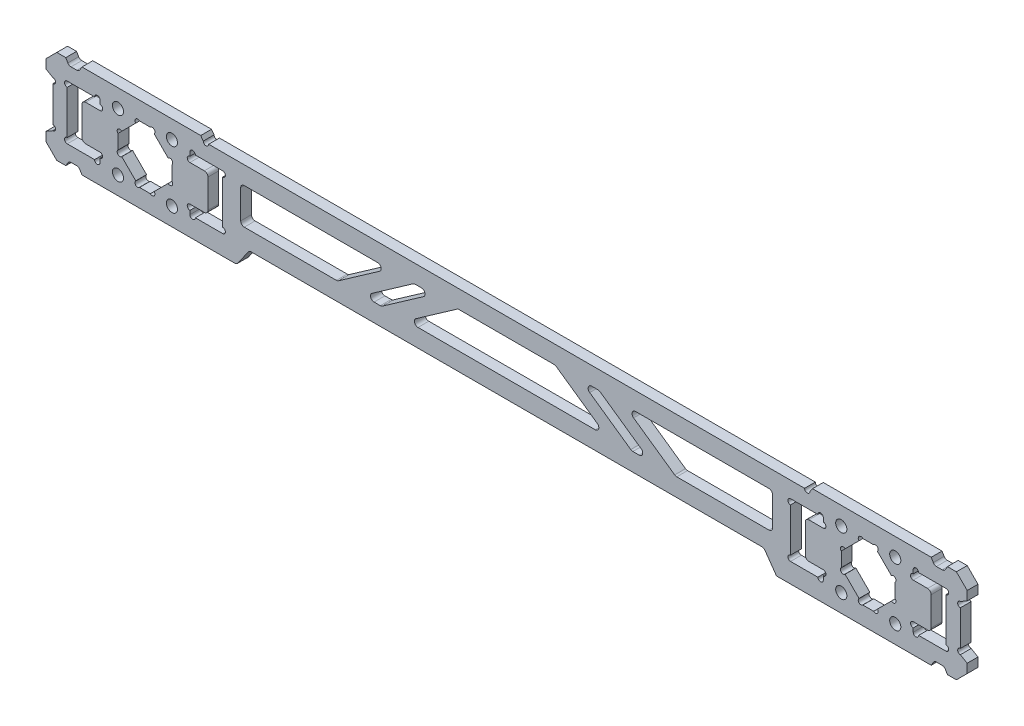
from build123d import *

# Parameters (mm, degrees)
SKETCH_1_W           = 256
SKETCH_1_H           = 26
SKETCH_1_R           = 1.55
EXTRUDE_1_DEPTH      = 1.5
CUT_EXTRUDE_1_DEPTH  = 4
SKETCH_3_R           = 0.75
CUT_EXTRUDE_2_DEPTH  = 4
FILLET_1_R           = 1
CUT_EXTRUDE_3_DEPTH  = 4
SKETCH_6_R           = 0.75
CUT_EXTRUDE_5_DEPTH  = 4
CHAMFER_1_SIZE       = 3
CUT_EXTRUDE_6_DEPTH  = 4
FILLET_2_R           = 1
CUT_EXTRUDE_7_DEPTH  = 4
SKETCH_9_R           = 0.75
CUT_EXTRUDE_8_DEPTH  = 4
CUT_EXTRUDE_9_DEPTH  = 4
SKETCH_11_R          = 0.75
CUT_EXTRUDE_10_DEPTH = 4
CUT_EXTRUDE_11_DEPTH = 4
CUT_EXTRUDE_12_DEPTH = 4
FILLET_3_R           = 1


with BuildPart() as part:
    # 草图1 → 凸台-拉伸1 (new body, symmetric)
    with BuildSketch(Plane.XY):
        Rectangle(SKETCH_1_W, SKETCH_1_H)
        with Locations((93, 8)):
            Circle(SKETCH_1_R, mode=Mode.SUBTRACT)
        with Locations((108, 8)):
            Circle(SKETCH_1_R, mode=Mode.SUBTRACT)
        with Locations((108, -8)):
            Circle(SKETCH_1_R, mode=Mode.SUBTRACT)
        with Locations((93, -8)):
            Circle(SKETCH_1_R, mode=Mode.SUBTRACT)
        with Locations((-93, 8)):
            Circle(SKETCH_1_R, mode=Mode.SUBTRACT)
        with Locations((-93, -8)):
            Circle(SKETCH_1_R, mode=Mode.SUBTRACT)
        with Locations((-108, -8)):
            Circle(SKETCH_1_R, mode=Mode.SUBTRACT)
        with Locations((-108, 8)):
            Circle(SKETCH_1_R, mode=Mode.SUBTRACT)
    extrude(amount=EXTRUDE_1_DEPTH, both=True)

    # 草图2 → 切除-拉伸1 (cut, through all)
    with BuildSketch(Plane.XY.offset(1.5)):
        Polygon((-113, 7.55), (-113, 5), (-118, 5), (-118, -5), (-113, -5), (-113, -7.55), (-122.1, -7.55), (-122.1, 7.55), align=None)
        Polygon((-78.9, -7.55), (-78.9, 7.55), (-88, 7.55), (-88, 5), (-83, 5), (-83, -5), (-88, -5), (-88, -7.55), align=None)
    cut_extrude_1 = extrude(amount=-CUT_EXTRUDE_1_DEPTH, mode=Mode.SUBTRACT)

    # 草图3 → 切除-拉伸2 (cut, through all)
    with BuildSketch(Plane.XY.offset(1.5)):
        with Locations((-113, 5.75)):
            Circle(SKETCH_3_R)
        with Locations((-113.75, 7.55)):
            Circle(SKETCH_3_R)
        with Locations((-122.1, 6.8)):
            Circle(SKETCH_3_R)
        with Locations((-122.1, -6.8)):
            Circle(SKETCH_3_R)
        with Locations((-113, -5.75)):
            Circle(SKETCH_3_R)
        with Locations((-113.75, -7.55)):
            Circle(SKETCH_3_R)
        with Locations((-88, 5.75)):
            Circle(SKETCH_3_R)
        with Locations((-87.25, 7.55)):
            Circle(SKETCH_3_R)
        with Locations((-88, -5.75)):
            Circle(SKETCH_3_R)
        with Locations((-87.25, -7.55)):
            Circle(SKETCH_3_R)
        with Locations((-78.9, 6.8)):
            Circle(SKETCH_3_R)
        with Locations((-78.9, -6.8)):
            Circle(SKETCH_3_R)
    cut_extrude_2 = extrude(amount=-CUT_EXTRUDE_2_DEPTH, mode=Mode.SUBTRACT)

    # 镜向1: 切除-拉伸1, 切除-拉伸2 across plane
    add(cut_extrude_1.mirror(Plane(origin=(0, 0, 0), x_dir=(0, 0, 1), z_dir=(1, 0, 0))), mode=Mode.SUBTRACT)
    add(cut_extrude_2.mirror(Plane(origin=(0, 0, 0), x_dir=(0, 0, 1), z_dir=(1, 0, 0))), mode=Mode.SUBTRACT)

    # 圆角1
    fillet_1_edges = [part.edges().sort_by_distance(p)[0] for p in [
        (118, -5, 0),
        (118, 5, 0),
        (83, 5, 0),
        (83, -5, 0),
        (-118, 5, 0),
        (-118, -5, 0),
        (-83, -5, 0),
        (-83, 5, 0),
    ]]
    fillet(fillet_1_edges, radius=FILLET_1_R)

    # 草图4 → 切除-拉伸3 (cut, through all)
    with BuildSketch(Plane.XY.offset(1.5)):
        Polygon((-128, 7.5), (-126.1, 6.403034489), (-126.1, -6.403034489), (-128, -7.5), align=None)
    cut_extrude_3 = extrude(amount=-CUT_EXTRUDE_3_DEPTH, mode=Mode.SUBTRACT)

    # 草图6 → 切除-拉伸5 (cut, through all)
    with BuildSketch(Plane.XY.offset(1.5)):
        with Locations((-126.1, 5.653034489)):
            Circle(SKETCH_6_R)
        with Locations((-126.1, -5.653034489)):
            Circle(SKETCH_6_R)
    cut_extrude_5 = extrude(amount=-CUT_EXTRUDE_5_DEPTH, mode=Mode.SUBTRACT)

    # 镜向2: 切除-拉伸3, 切除-拉伸5 across plane
    add(cut_extrude_3.mirror(Plane(origin=(0, 0, 0), x_dir=(0, 0, 1), z_dir=(1, 0, 0))), mode=Mode.SUBTRACT)
    add(cut_extrude_5.mirror(Plane(origin=(0, 0, 0), x_dir=(0, 0, 1), z_dir=(1, 0, 0))), mode=Mode.SUBTRACT)

    # 倒角1
    chamfer_1_edges = [part.edges().sort_by_distance(p)[0] for p in [
        (-128, 13, 0),
        (128, 13, 0),
        (128, -13, 0),
        (-128, -13, 0),
    ]]
    chamfer(chamfer_1_edges, length=CHAMFER_1_SIZE)

    # 草图7 → 切除-拉伸6 (cut, through all)
    with BuildSketch(Plane.XY.offset(1.5)):
        Polygon((-122.5, 13), (-121.633974596, 11.5), (-118.866025404, 11.5), (-118, 13), align=None)
        Polygon((-118.866025404, -11.5), (-118, -13), (-122.5, -13), (-121.633974596, -11.5), align=None)
    cut_extrude_6 = extrude(amount=-CUT_EXTRUDE_6_DEPTH, mode=Mode.SUBTRACT)

    # 镜向3: 切除-拉伸6 across plane
    add(cut_extrude_6.mirror(Plane(origin=(0, 0, 0), x_dir=(0, 0, 1), z_dir=(1, 0, 0))), mode=Mode.SUBTRACT)

    # 圆角2
    fillet_2_edges = [part.edges().sort_by_distance(p)[0] for p in [
        (-118.866025404, 11.5, 0),
        (-121.633974596, 11.5, 0),
        (-121.633974596, -11.5, 0),
        (-118.866025404, -11.5, 0),
        (121.633974596, 11.5, 0),
        (118.866025404, 11.5, 0),
        (118.866025404, -11.5, 0),
        (121.633974596, -11.5, 0),
    ]]
    fillet(fillet_2_edges, radius=FILLET_2_R)

    # 草图8 → 切除-拉伸7 (cut, through all)
    with BuildSketch(Plane.XY.offset(1.5)):
        Polygon((-108, 2), (-108, -2), (-102, -8), (-99, -8), (-93, -2), (-93, 2), (-99, 8), (-102, 8), align=None)
    cut_extrude_7 = extrude(amount=-CUT_EXTRUDE_7_DEPTH, mode=Mode.SUBTRACT)

    # 草图9 → 切除-拉伸8 (cut, through all)
    with BuildSketch(Plane.XY.offset(1.5)):
        with Locations((-107.469669914, 2.530330086)):
            Circle(SKETCH_9_R)
        with Locations((-102.530330086, 7.469669914)):
            Circle(SKETCH_9_R)
        with Locations((-98.469669914, 7.469669914)):
            Circle(SKETCH_9_R)
        with Locations((-93.530330086, 2.530330086)):
            Circle(SKETCH_9_R)
        with Locations((-93.530330086, -2.530330086)):
            Circle(SKETCH_9_R)
        with Locations((-98.469669914, -7.469669914)):
            Circle(SKETCH_9_R)
        with Locations((-102.530330086, -7.469669914)):
            Circle(SKETCH_9_R)
        with Locations((-107.469669914, -2.530330086)):
            Circle(SKETCH_9_R)
    cut_extrude_8 = extrude(amount=-CUT_EXTRUDE_8_DEPTH, mode=Mode.SUBTRACT)

    # 镜向4: 切除-拉伸7, 切除-拉伸8 across plane
    add(cut_extrude_7.mirror(Plane(origin=(0, 0, 0), x_dir=(0, 0, 1), z_dir=(1, 0, 0))), mode=Mode.SUBTRACT)
    add(cut_extrude_8.mirror(Plane(origin=(0, 0, 0), x_dir=(0, 0, 1), z_dir=(1, 0, 0))), mode=Mode.SUBTRACT)

    # 草图10 → 切除-拉伸9 (cut, through all)
    with BuildSketch(Plane.XY.offset(1.5)):
        Polygon((84.299792462, 12), (85, 13), (-85, 13), (-84.299792462, 12), align=None)
    extrude(amount=-CUT_EXTRUDE_9_DEPTH, mode=Mode.SUBTRACT)

    # 草图11 → 切除-拉伸10 (cut, through all)
    with BuildSketch(Plane.XY.offset(1.5)):
        with Locations((-83.549792462, 12)):
            Circle(SKETCH_11_R)
        with Locations((83.549792462, 12)):
            Circle(SKETCH_11_R)
    extrude(amount=-CUT_EXTRUDE_10_DEPTH, mode=Mode.SUBTRACT)

    # 草图13 → 切除-拉伸11 (cut, through all)
    with BuildSketch(Plane(origin=(0, 0, -1.5), x_dir=(-1, 0, 0), z_dir=(0, 0, -1))):
        Polygon((-75, -13), (-71.498962309, -8), (71.498962309, -8), (75, -13), align=None)
    extrude(amount=-CUT_EXTRUDE_11_DEPTH, mode=Mode.SUBTRACT)

    # 草图14 → 切除-拉伸12 (cut, through all)
    with BuildSketch(Plane.XY.offset(1.5)):
        Polygon((-73.9, 7), (-73.9, -3), (-46.973787182, -3), (-32.692307115, 7), align=None)
        Polygon((-25.718519933, 7), (-40, -3), (-34.769659613, -3), (-20.488179546, 7), align=None)
        Polygon((25.718519933, 7), (20.488179546, 7), (34.769659613, -3), (40, -3), align=None)
        Polygon((46.973787182, -3), (32.692307115, 7), (73.9, 7), (73.9, -3), align=None)
        Polygon((-13.514392363, 7), (-27.795872431, -3), (27.795872431, -3), (13.514392363, 7), align=None)
    extrude(amount=-CUT_EXTRUDE_12_DEPTH, mode=Mode.SUBTRACT)

    # 圆角3
    fillet_3_edges = [part.edges().sort_by_distance(p)[0] for p in [
        (-75, -13, 0),
        (71.498962309, -8, 0),
        (-71.498962309, -8, 0),
        (-13.514392363, 7, 0),
        (13.514392363, 7, 0),
        (27.795872431, -3, 0),
        (-27.795872431, -3, 0),
        (-25.718519933, 7, 0),
        (-20.488179546, 7, 0),
        (-34.769659613, -3, 0),
        (-40, -3, 0),
        (73.9, -3, 0),
        (46.973787182, -3, 0),
        (32.692307115, 7, 0),
        (73.9, 7, 0),
        (40, -3, 0),
        (34.769659613, -3, 0),
        (20.488179546, 7, 0),
        (25.718519933, 7, 0),
        (-73.9, 7, 0),
        (-32.692307115, 7, 0),
        (-46.973787182, -3, 0),
        (-73.9, -3, 0),
    ]]
    fillet(fillet_3_edges, radius=FILLET_3_R)


solid = part.part
